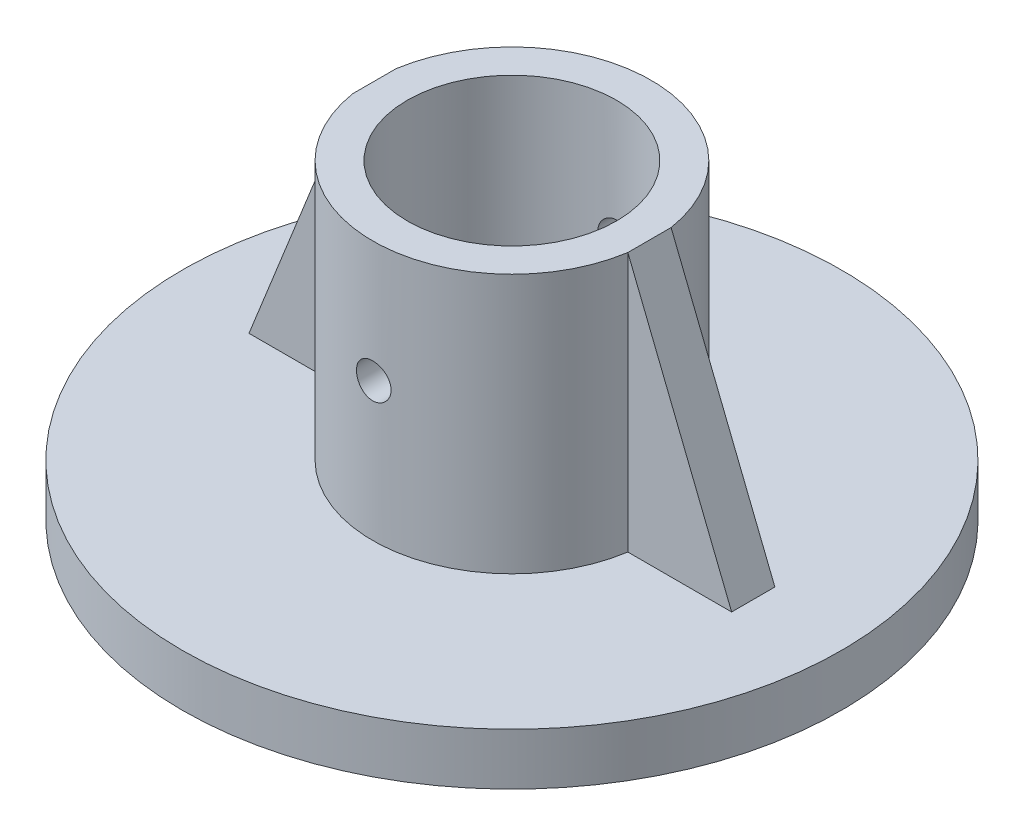
from build123d import *

# Parameters (mm, degrees)
IZIM1_R                      = 19.054564863
Y_KSEKLIK_EKSTR_ZYON1_DEPTH  = 3
IZIM1_3_R                    = 8.05
IZIM1_3_R_2                  = 6.05
Y_KSEKLIK_EKSTR_ZYON2_DEPTH  = 18
Y_KSEKLIK_EKSTR_ZYON10_DEPTH = 18
KES_EKSTR_ZYON1_DEPTH        = 20.054564863
KES_EKSTR_ZYON1_DEPTH_BACK   = 20.054564863
IZIM6_R                      = 1
KES_EKSTR_ZYON2_DEPTH        = 20.054564863
KES_EKSTR_ZYON2_DEPTH_BACK   = 20.054564863


with BuildPart() as part:
    # Çizim1 → Yükseklik-Ekstrüzyon1 (new body)
    with BuildSketch(Plane(origin=(0, 0, 0), x_dir=(1, 0, 0), z_dir=(0, 1, 0))):
        Circle(IZIM1_R)
    extrude(amount=Y_KSEKLIK_EKSTR_ZYON1_DEPTH)

    # Çizim1<3> → Yükseklik-Ekstrüzyon2 (add)
    with BuildSketch(Plane(origin=(0, 0, 0), x_dir=(1, 0, 0), z_dir=(0, 1, 0))):
        Circle(IZIM1_3_R)
        Circle(IZIM1_3_R_2, mode=Mode.SUBTRACT)
    extrude(amount=Y_KSEKLIK_EKSTR_ZYON2_DEPTH)

    # Çizim1<11> → Yükseklik-Ekstrüzyon10 (add)
    with BuildSketch(Plane(origin=(0, 0, 0), x_dir=(1, 0, 0), z_dir=(0, 1, 0))):
        with BuildLine():
            ThreePointArc((-7.952358141, -1.25), (-8.05, 0), (-7.952358141, 1.25))
            Line((-7.952358141, 1.25), (-13.952358141, 1.25))
            Line((-13.952358141, 1.25), (-13.952358141, -1.25))
            Line((-13.952358141, -1.25), (-7.952358141, -1.25))
        make_face()
        with BuildLine():
            Line((13.952358141, 1.25), (7.952358141, 1.25))
            ThreePointArc((7.952358141, 1.25), (8.025552412, 0.626903887), (8.05, 0))
            ThreePointArc((8.05, 0), (8.025552412, -0.626903887), (7.952358141, -1.25))
            Line((7.952358141, -1.25), (13.952358141, -1.25))
            Line((13.952358141, -1.25), (13.952358141, 1.25))
        make_face()
    extrude(amount=Y_KSEKLIK_EKSTR_ZYON10_DEPTH)

    # Çizim5 → Kes-Ekstrüzyon1 (cut, two sides)
    with BuildSketch(Plane.XY) as kes_ekstr_zyon1_sk:
        Polygon((-13.952358141, 3), (-7.952358141, 18), (-13.952358141, 18), align=None)
        Polygon((7.952358141, 18), (13.952358141, 18), (13.952358141, 3), align=None)
    extrude(amount=KES_EKSTR_ZYON1_DEPTH, mode=Mode.SUBTRACT)
    extrude(kes_ekstr_zyon1_sk.sketch, amount=-KES_EKSTR_ZYON1_DEPTH_BACK, mode=Mode.SUBTRACT)

    # Çizim6 → Kes-Ekstrüzyon2 (cut, two sides)
    with BuildSketch(Plane.XY) as kes_ekstr_zyon2_sk:
        with Locations((0, 11)):
            Circle(IZIM6_R)
    extrude(amount=KES_EKSTR_ZYON2_DEPTH, mode=Mode.SUBTRACT)
    extrude(kes_ekstr_zyon2_sk.sketch, amount=-KES_EKSTR_ZYON2_DEPTH_BACK, mode=Mode.SUBTRACT)


solid = part.part
